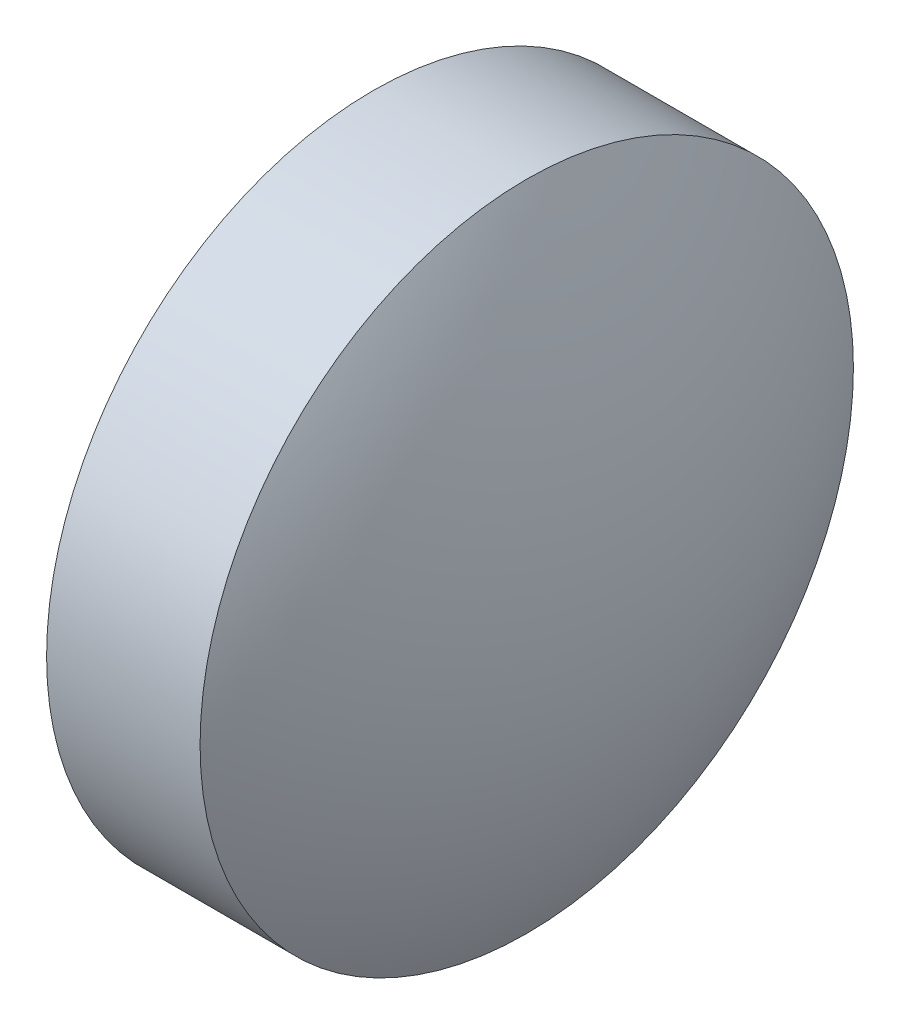
from build123d import *


with BuildPart() as part:
    # 草图1 → 旋转1 (revolve)
    with BuildSketch(Plane.XY):
        with BuildLine():
            Line((532.313507864, 77.220526373), (532.313507864, 80.370526373))
            Line((532.313507864, 80.370526373), (533.793507864, 80.370526373))
            ThreePointArc((533.793507864, 80.370526373), (534.405147813, 78.848016772), (534.613507864, 77.220526373))
            Line((534.613507864, 77.220526373), (532.313507864, 77.220526373))
        make_face()
    revolve(axis=Axis((531.451879695, 77.220526373, 0), (1, 0, 0)))


solid = part.part
